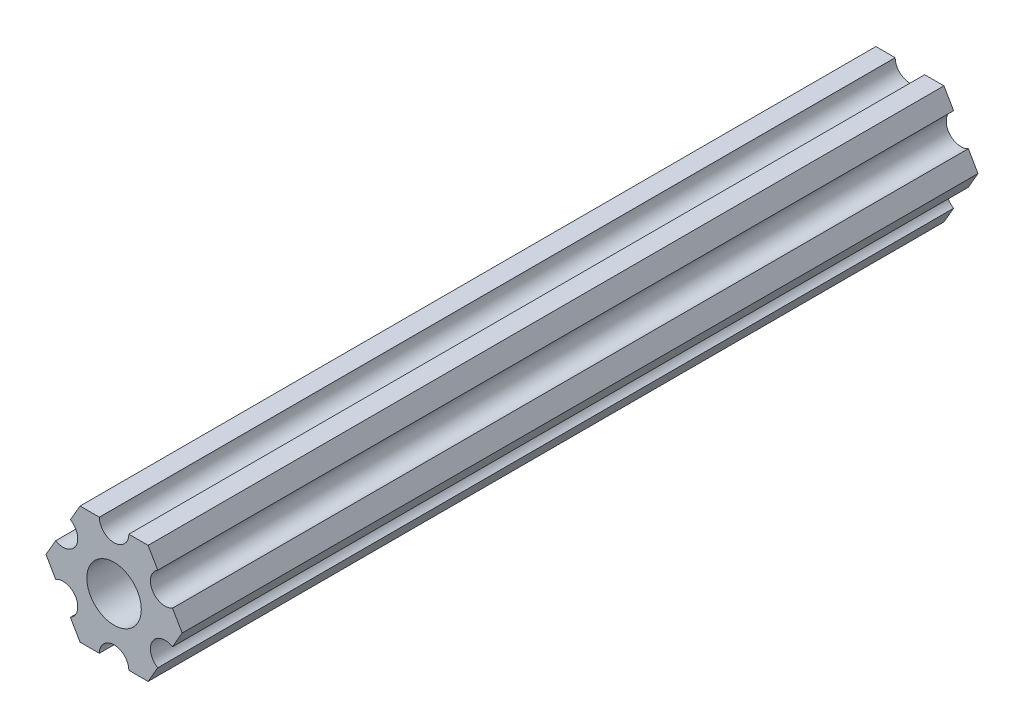
from build123d import *

# Parameters (mm, degrees)
SKETCH1_R           = 2.9337
BOSS_EXTRUDE1_DEPTH = 85.725


with BuildPart() as part:
    # Sketch1 → Boss-Extrude1 (new body)
    with BuildSketch(Plane.XY):
        with BuildLine():
            Line((-1.587500385, 6.349999904), (-3.666174594, 6.349999778))
            Line((-3.666174594, 6.349999778), (-4.70551159, 4.549815043))
            ThreePointArc((-4.70551159, 4.549815043), (-4.12444613, 2.38124975), (-6.293011423, 1.80018429))
            Line((-6.293011423, 1.80018429), (-7.332348419, -4.44e-07))
            Line((-7.332348419, -4.44e-07), (-6.293011205, -1.800185053))
            ThreePointArc((-6.293011205, -1.800185053), (-4.124445841, -2.38125025), (-4.705511038, -4.549815614))
            Line((-4.705511038, -4.549815614), (-3.666173825, -6.350000222))
            Line((-3.666173825, -6.350000222), (-1.587499615, -6.350000096))
            ThreePointArc((-1.587499615, -6.350000096), (2.89e-07, -4.7625), (1.587500385, -6.349999904))
            Line((1.587500385, -6.349999904), (3.666174594, -6.349999778))
            Line((3.666174594, -6.349999778), (4.70551159, -4.549815043))
            ThreePointArc((4.70551159, -4.549815043), (4.12444613, -2.38124975), (6.293011423, -1.80018429))
            Line((6.293011423, -1.80018429), (7.332348419, 4.44e-07))
            Line((7.332348419, 4.44e-07), (6.293011205, 1.800185053))
            ThreePointArc((6.293011205, 1.800185053), (4.124445841, 2.38125025), (4.705511038, 4.549815614))
            Line((4.705511038, 4.549815614), (3.666173825, 6.350000222))
            Line((3.666173825, 6.350000222), (1.587499615, 6.350000096))
            ThreePointArc((1.587499615, 6.350000096), (-2.89e-07, 4.7625), (-1.587500385, 6.349999904))
        make_face()
        Circle(SKETCH1_R, mode=Mode.SUBTRACT)
    extrude(amount=BOSS_EXTRUDE1_DEPTH)


solid = part.part
